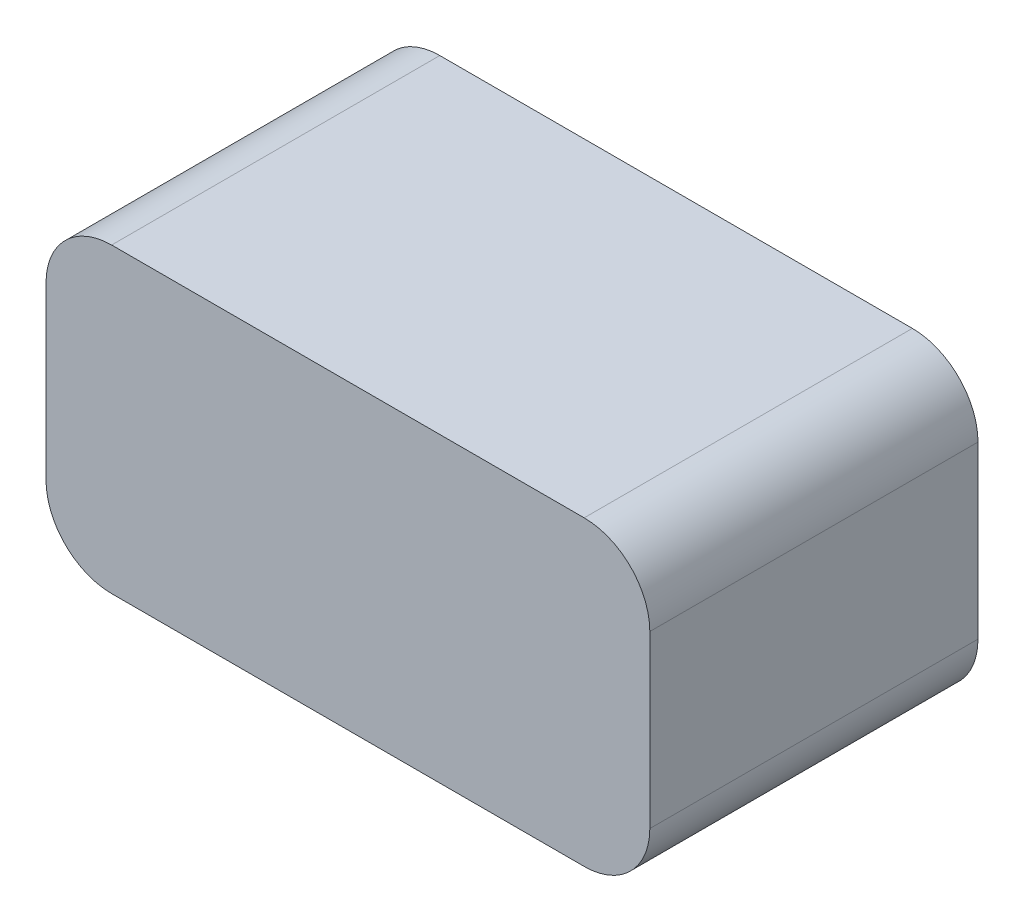
from build123d import *

# Parameters (mm, degrees)
SKETCH1_W           = 46
SKETCH1_H           = 25
BOSS_EXTRUDE1_DEPTH = 23
FILLET1_R           = 5


with BuildPart() as part:
    # Sketch1 → Boss-Extrude1 (new body)
    with BuildSketch(Plane(origin=(0, 0, 0), x_dir=(1, 0, 0), z_dir=(0, 1, 0))):
        with Locations((23, 12.5)):
            Rectangle(SKETCH1_W, SKETCH1_H)
    extrude(amount=BOSS_EXTRUDE1_DEPTH)

    # Fillet1
    fillet1_edges = [part.edges().sort_by_distance(p)[0] for p in [
        (46, 23, -12.5),
        (0, 23, -12.5),
        (46, 0, -12.5),
        (0, 0, -12.5),
    ]]
    fillet(fillet1_edges, radius=FILLET1_R)


solid = part.part
